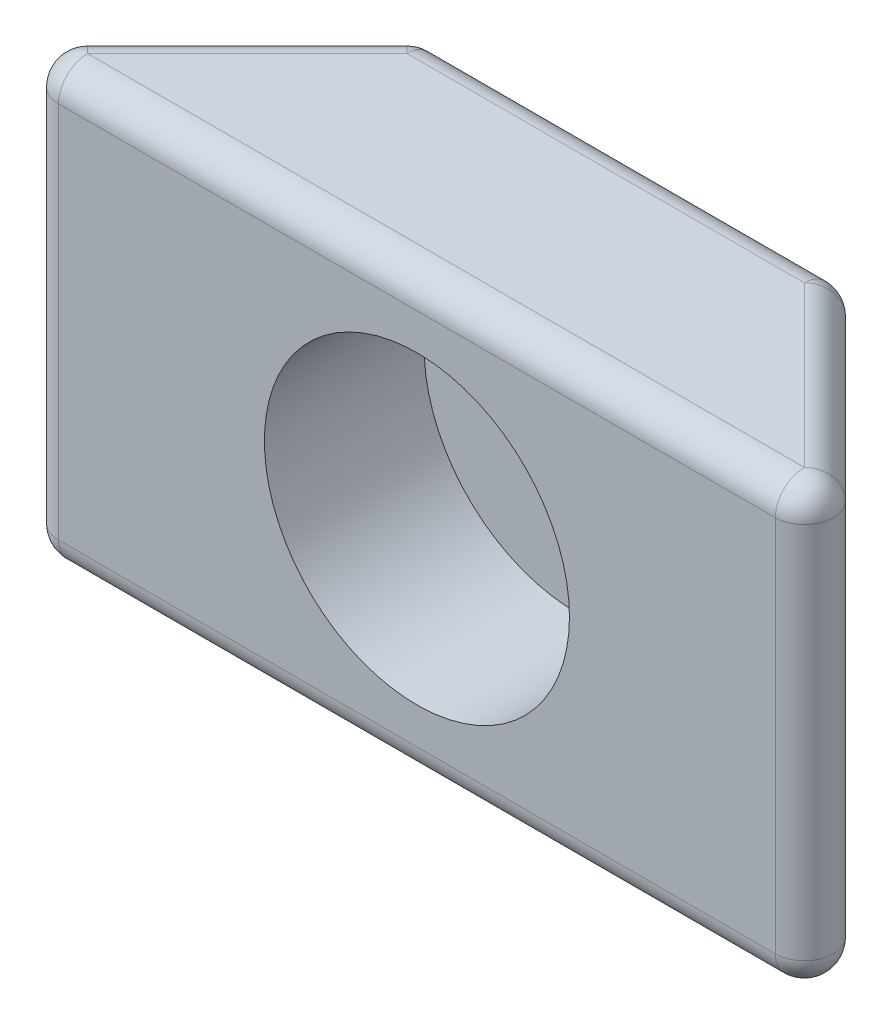
from build123d import *

# Parameters (mm, degrees)
EXTRUDE_1_DEPTH     = 3
SKETCH_3_R          = 2.1
CUT_EXTRUDE_1_DEPTH = 2.2
FILLET_1_R          = 0.4


with BuildPart() as part:
    # 草图2 → 凸台-拉伸1 (new body, symmetric)
    with BuildSketch(Plane(origin=(0, 0, 0), x_dir=(1, 0, 0), z_dir=(0, 1, 0))):
        Polygon((-5.9, 0), (5.9, 0), (2.9, 3), (-2.9, 3), align=None)
    extrude(amount=EXTRUDE_1_DEPTH, both=True)

    # 草图3 → 切除-拉伸1 (cut)
    with BuildSketch(Plane.XY):
        Circle(SKETCH_3_R)
    extrude(amount=-CUT_EXTRUDE_1_DEPTH, mode=Mode.SUBTRACT)

    # 圆角1
    fillet_1_edges = [part.edges().sort_by_distance(p)[0] for p in [
        (4.4, 3, -1.5),
        (0, 3, -3),
        (-4.4, 3, -1.5),
        (0, -3, -3),
        (4.4, -3, -1.5),
        (0, -3, 0),
        (-4.4, -3, -1.5),
        (-2.9, 0, -3),
        (2.9, 0, -3),
        (5.9, 0, 0),
        (-5.9, 0, 0),
        (0, 3, 0),
    ]]
    fillet(fillet_1_edges, radius=FILLET_1_R)


solid = part.part
